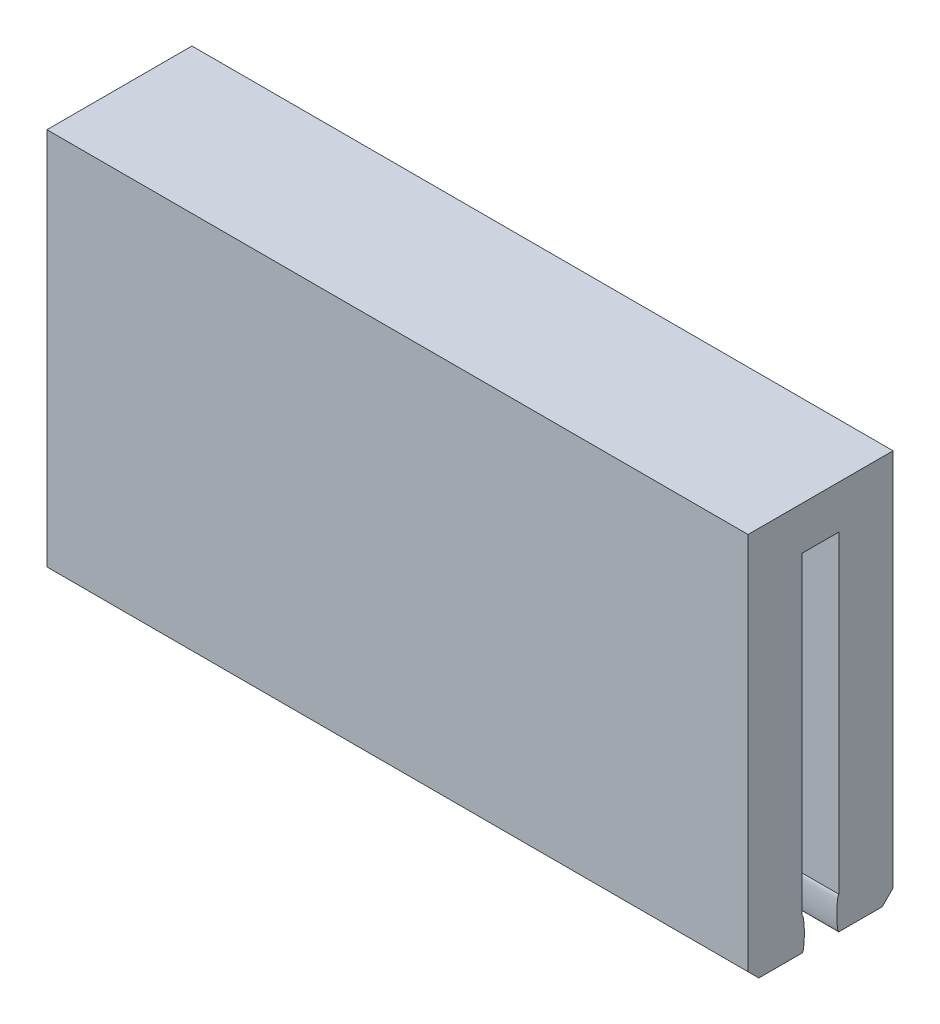
from build123d import *

# Parameters (mm, degrees)
BOSS_EXTRUDE1_DEPTH   = 16
BOSS_EXTRUDE1_2_DEPTH = 16
SKETCH2_W             = 32.4
SKETCH2_H             = 6.7
BOSS_EXTRUDE2_DEPTH   = 2
CHAMFER1_SIZE         = 0.5
CHAMFER1_SIZE2        = 4.072173214
CHAMFER1_PART_2_SIZE  = 0.5
CHAMFER1_PART_2_SIZE2 = 4.072173214
CHAMFER4_SIZE         = 0.5
SKETCH4_RX            = 0.75
SKETCH4_RY            = 0.1
BOSS_EXTRUDE3_DEPTH   = 2
SKETCH5_RX            = 0.75
SKETCH5_RY            = 0.1
BOSS_EXTRUDE4_DEPTH   = 2


with BuildPart() as part:
    # Sketch1 → Boss-Extrude1 (new body)
    with BuildSketch(Plane(origin=(0, 0, 0), x_dir=(1, 0, 0), z_dir=(0, 1, 0))):
        Polygon((-14.2, 0.85), (-16.2, 0.85), (-16.2, 3.35), (16.2, 3.35), (16.2, 0.85), (14.2, 0.85), (14.2, 1.35), (-14.2, 1.35), align=None)
    extrude(amount=BOSS_EXTRUDE1_DEPTH)



with BuildPart() as body_2:
    # Sketch1 → Boss-Extrude1 2 (new body)
    with BuildSketch(Plane(origin=(0, 0, 0), x_dir=(1, 0, 0), z_dir=(0, 1, 0))):
        Polygon((-16.2, -3.35), (16.2, -3.35), (16.2, -0.85), (14.2, -0.85), (14.2, -1.35), (-14.2, -1.35), (-14.2, -0.85), (-16.2, -0.85), align=None)
    extrude(amount=BOSS_EXTRUDE1_2_DEPTH)


with BuildPart() as part_1:
    add(part.part)

    add(body_2.part)  # Boss-Extrude2 merges body 2
    # Sketch2 → Boss-Extrude2 (add)
    with BuildSketch(Plane(origin=(0, 16, 0), x_dir=(1, 0, 0), z_dir=(0, 1, 0))):
        Rectangle(SKETCH2_W, SKETCH2_H)
    extrude(amount=BOSS_EXTRUDE2_DEPTH)

    # Chamfer1
    chamfer1_edges = [part_1.edges().sort_by_distance(p)[0] for p in [
        (0, 0, 1.35),
    ]]
    chamfer1_side = [part_1.faces().sort_by_distance(p)[0] for p in [
        (0, 0, 2.31257485),
    ]]
    chamfer(chamfer1_edges, length=CHAMFER1_SIZE, length2=CHAMFER1_SIZE2, reference=chamfer1_side[0])

    # Chamfer1 part 2
    chamfer1_part_2_edges = [part_1.edges().sort_by_distance(p)[0] for p in [
        (0, 0, -1.35),
    ]]
    chamfer1_part_2_side = [part_1.faces().sort_by_distance(p)[0] for p in [
        (0, 0, -2.31257485),
    ]]
    chamfer(chamfer1_part_2_edges, length=CHAMFER1_PART_2_SIZE, length2=CHAMFER1_PART_2_SIZE2, reference=chamfer1_part_2_side[0])

    # Chamfer4
    chamfer4_edges = [part_1.edges().sort_by_distance(p)[0] for p in [
        (0, 0, -3.35),
        (0, 0, 3.35),
    ]]
    chamfer(chamfer4_edges, length=CHAMFER4_SIZE)

    # Sketch4 → Boss-Extrude3 (add)
    with BuildSketch(Plane(origin=(16.2, 0, 0), x_dir=(0, 0, -1), z_dir=(1, 0, 0))):
        with Locations(Location((-0.85, 0.75), (0, 0, 90))):
            Ellipse(SKETCH4_RX, SKETCH4_RY)
        with Locations(Location((0.85, 0.75), (0, 0, 90))):
            Ellipse(SKETCH4_RX, SKETCH4_RY)
    extrude(amount=-BOSS_EXTRUDE3_DEPTH)

    # Sketch5 → Boss-Extrude4 (add)
    with BuildSketch(Plane.ZY.offset(16.2)):
        with Locations(Location((-0.85, 0.75), (0, 0, -90))):
            Ellipse(SKETCH5_RX, SKETCH5_RY)
        with Locations(Location((0.85, 0.75), (0, 0, -90))):
            Ellipse(SKETCH5_RX, SKETCH5_RY)
    extrude(amount=-BOSS_EXTRUDE4_DEPTH)


solid = part_1.part
